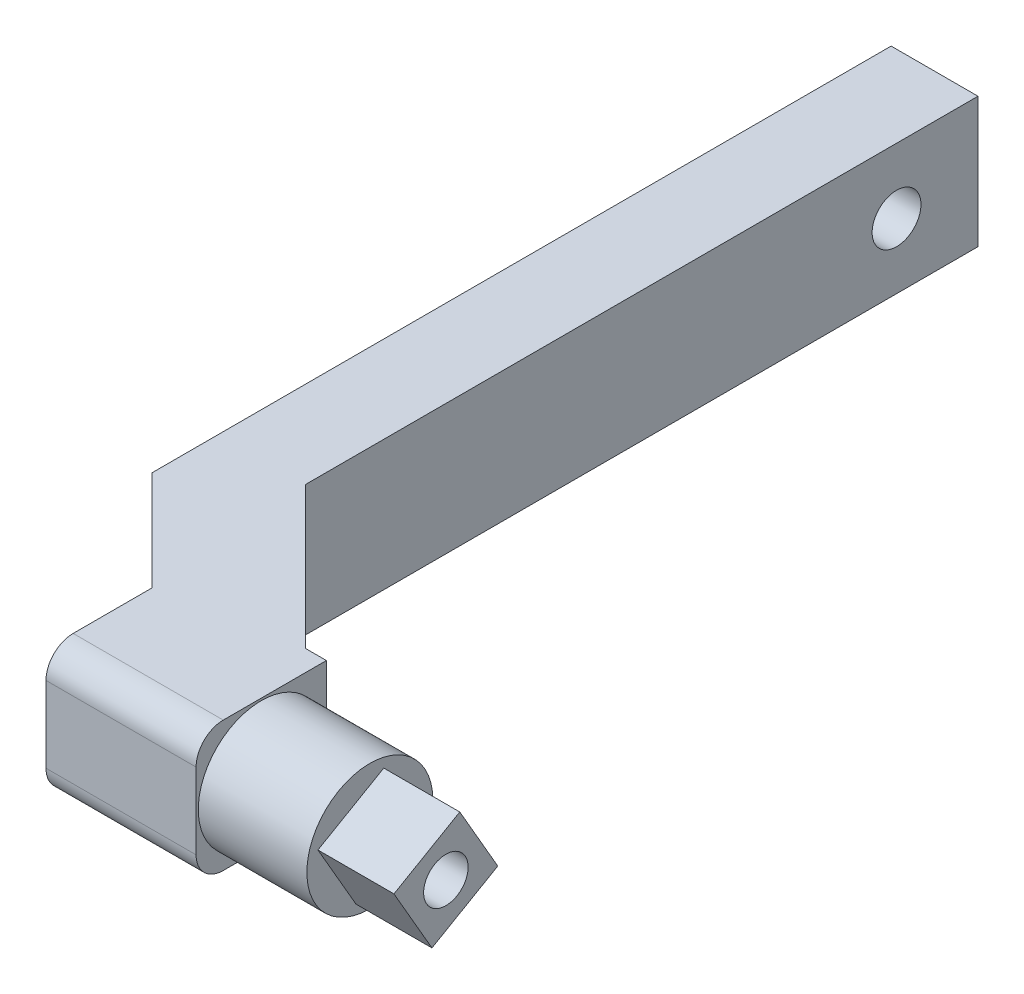
from build123d import *

# Parameters (mm, degrees)
EXTRUDE_1_DEPTH          = 24
SKETCH_2_W               = 24
SKETCH_2_H               = 24
SKETCH_2_R               = 11.6
CUT_EXTRUDE_1_DEPTH      = 20
SKETCH_6_R               = 4.1
CUT_EXTRUDE_3_DEPTH      = 1
CUT_EXTRUDE_3_DEPTH_BACK = 67
FILLET_3_R               = 5
EXTRUDE_2_DEPTH          = 14
SKETCH_10_R              = 4.1
CUT_EXTRUDE_4_DEPTH      = 81
SKETCH_12_R              = 11.1
CUT_EXTRUDE_5_DEPTH      = 7.1
SKETCH_13_R              = 4.5
CUT_EXTRUDE_6_DEPTH      = 73.9


with BuildPart() as part:
    # Эскиз1 → Бобышка-Вытянуть1 (new body)
    with BuildSketch(Plane(origin=(0, 0, 0), x_dir=(1, 0, 0), z_dir=(0, 1, 0))):
        Polygon((-37.857864376, 37.857864376), (-36, 36), (-36, 159.857864376), (-52, 159.857864376), (-52, 23.715728753), align=None)
        Polygon((-36, 23.715728753), (-36, 36), (-37.857864376, 37.857864376), (-52, 23.715728753), align=None)
        Polygon((-33.642135624, 5.357864376), (-14.142135624, -14.142135624), (-14.142135624, 9.857864376), (-9.857864376, 9.857864376), (-36, 36), (-36, 23.715728753), (-52, 23.715728753), align=None)
        Polygon((-14.142135624, -14.142135624), (0, 0), (-9.857864376, 9.857864376), (-14.142135624, 9.857864376), align=None)
        Polygon((-9.857864376, 9.857864376), (0, 0), (-14.142135624, -14.142135624), (14, -14.142135624), (14, 9.857864376), align=None)
        Polygon((-33.642135624, -14.142135624), (-14.142135624, -14.142135624), (-33.642135624, 5.357864376), align=None)
    extrude(amount=EXTRUDE_1_DEPTH)

    # Эскиз2 → Вырез-Вытянуть1 (cut)
    with BuildSketch(Plane(origin=(14, 0, 0), x_dir=(0, 0, -1), z_dir=(1, 0, 0))):
        with Locations((-2.142135624, 12)):
            Rectangle(SKETCH_2_W, SKETCH_2_H)
        with Locations((-2.142135624, 12)):
            Circle(SKETCH_2_R, mode=Mode.SUBTRACT)
    extrude(amount=-CUT_EXTRUDE_1_DEPTH, mode=Mode.SUBTRACT)

    # Эскиз6 → Вырез-Вытянуть3 (cut, two sides)
    with BuildSketch(Plane(origin=(14, 0, 0), x_dir=(0, 0, -1), z_dir=(1, 0, 0))) as cut_extrude_3_sk:
        with Locations((-2.142135624, 12)):
            Circle(SKETCH_6_R)
    extrude(amount=CUT_EXTRUDE_3_DEPTH, mode=Mode.SUBTRACT)
    extrude(cut_extrude_3_sk.sketch, amount=-CUT_EXTRUDE_3_DEPTH_BACK, mode=Mode.SUBTRACT)

    # Скругление3
    fillet_3_edges = [part.edges().sort_by_distance(p)[0] for p in [
        (-19.821067812, 0, 14.142135624),
        (-19.821067812, 24, 14.142135624),
    ]]
    fillet(fillet_3_edges, radius=FILLET_3_R)

    # Эскиз9 → Бобышка-Вытянуть2 (add)
    with BuildSketch(Plane(origin=(14, 0, 0), x_dir=(0, 0, -1), z_dir=(1, 0, 0))):
        Polygon((0.420042203, 21.562177826), (-11.70431345, 14.562177826), (-4.70431345, 2.437822174), (7.420042203, 9.437822174), align=None)
    extrude(amount=EXTRUDE_2_DEPTH)

    # Эскиз10 → Вырез-Вытянуть4 (cut, through all)
    with BuildSketch(Plane(origin=(28, 0, 0), x_dir=(0, 0, -1), z_dir=(1, 0, 0))):
        with Locations((-2.142135624, 12)):
            Circle(SKETCH_10_R)
    extrude(amount=-CUT_EXTRUDE_4_DEPTH, mode=Mode.SUBTRACT)

    # Эскиз12 → Вырез-Вытянуть5 (cut)
    with BuildSketch(Plane.ZY.offset(52)):
        with Locations((-144.857864376, 12)):
            Circle(SKETCH_12_R)
    extrude(amount=-CUT_EXTRUDE_5_DEPTH, mode=Mode.SUBTRACT)

    # Эскиз13 → Вырез-Вытянуть6 (cut, through all)
    with BuildSketch(Plane.ZY.offset(44.9)):
        with Locations((-144.857864376, 12)):
            Circle(SKETCH_13_R)
    extrude(amount=-CUT_EXTRUDE_6_DEPTH, mode=Mode.SUBTRACT)


solid = part.part
